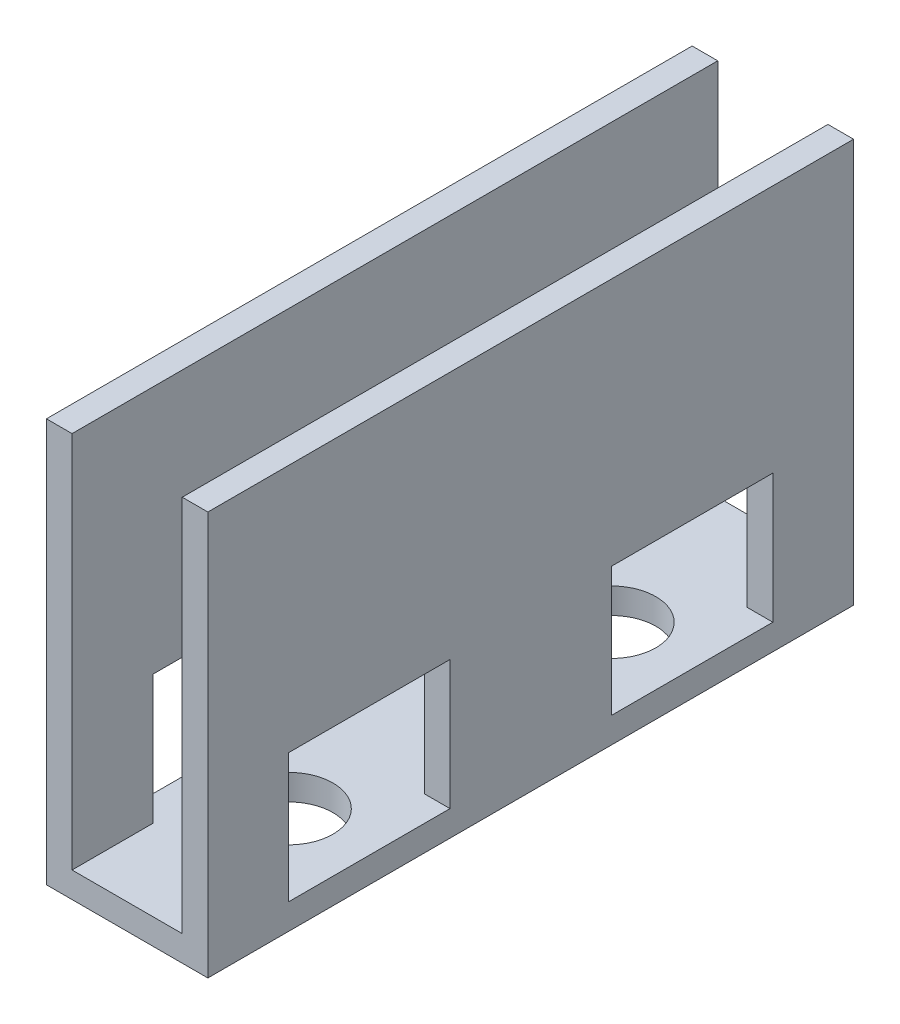
from build123d import *

# Parameters (mm, degrees)
SKETCH1_W           = 10
SKETCH1_H           = 40
SKETCH1_R           = 2.75
BOSS_EXTRUDE1_DEPTH = 1.5875
SKETCH1_3_W         = 1.5875
SKETCH1_3_H         = 40
BOSS_EXTRUDE2_DEPTH = 25
SKETCH2_W           = 10
SKETCH2_H           = 8
CUT_EXTRUDE1_DEPTH  = 34.541019662


with BuildPart() as part:
    # Sketch1 → Boss-Extrude1 (new body)
    with BuildSketch(Plane(origin=(0, 0, 0), x_dir=(1, 0, 0), z_dir=(0, 1, 0))):
        Rectangle(SKETCH1_W, SKETCH1_H)
        with Locations((0, -10)):
            Circle(SKETCH1_R, mode=Mode.SUBTRACT)
        with Locations((0, 10)):
            Circle(SKETCH1_R, mode=Mode.SUBTRACT)
    extrude(amount=BOSS_EXTRUDE1_DEPTH)

    # Sketch1_3 → Boss-Extrude2 (add)
    with BuildSketch(Plane(origin=(0, 0, 0), x_dir=(1, 0, 0), z_dir=(0, 1, 0))):
        with Locations((-4.20625, 0)):
            Rectangle(SKETCH1_3_W, SKETCH1_3_H)
        with Locations((4.20625, 0)):
            Rectangle(SKETCH1_3_W, SKETCH1_3_H)
    extrude(amount=BOSS_EXTRUDE2_DEPTH)

    # Sketch2 → Cut-Extrude1 (cut, through all)
    with BuildSketch(Plane(origin=(5, 0, 0), x_dir=(0, 0, -1), z_dir=(1, 0, 0))):
        with Locations((-10, 5.5875)):
            Rectangle(SKETCH2_W, SKETCH2_H)
        with Locations((10, 5.5875)):
            Rectangle(SKETCH2_W, SKETCH2_H)
    extrude(amount=-CUT_EXTRUDE1_DEPTH, mode=Mode.SUBTRACT)


solid = part.part
